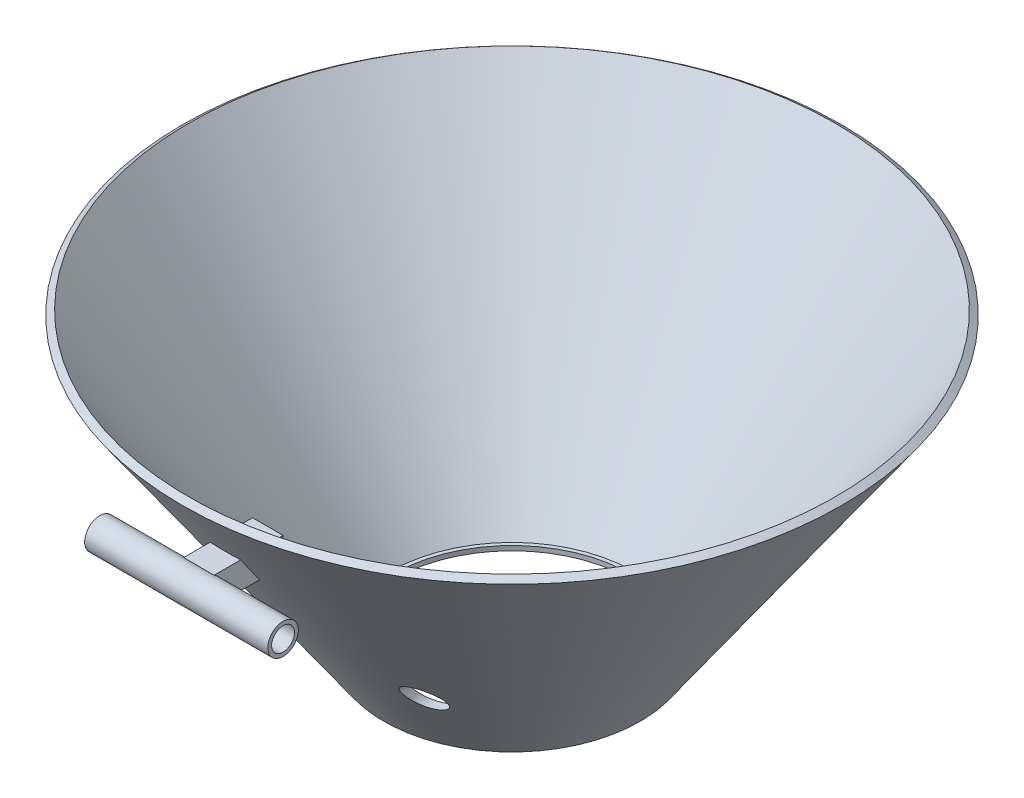
from build123d import *

# Parameters (mm, degrees)
CUT_EXTRUDE1_REACH       = 37.892
SKETCH4_R                = 7.75
BOSS_EXTRUDE1_DEPTH      = 3
BOSS_EXTRUDE1_DEPTH_BACK = 2
BOSS_EXTRUDE1_START      = 18
SKETCH13_W               = 2
SKETCH13_H               = 1.751149917
BOSS_EXTRUDE2_DEPTH      = 5
BOSS_EXTRUDE2_DEPTH_BACK = 7
SKETCH14_R               = 1
SKETCH15_R               = 0.75
CUT_EXTRUDE2_DEPTH       = 15
SKETCH16_R               = 1
CUT_EXTRUDE3_DEPTH       = 20


with BuildPart() as part:
    # Sketch3 → Revolve1 (revolve)
    with BuildSketch(Plane.XY):
        Polygon((8.400325033, 0), (21.601834058, 18.8537088), (21.192258036, 19.140497019), (8, 0.3), (0, 0.3), (0, 0), align=None)
    revolve(axis=Axis((0, 0, 0), (0, 1, 0)))

    # Sketch4 → Cut-Extrude1 (cut, up to next)
    with BuildSketch(Plane(origin=(0, 0.3, 0), x_dir=(1, 0, 0), z_dir=(0, 1, 0)), mode=Mode.PRIVATE) as cut_extrude1_sk1:
        Circle(SKETCH4_R)
    cut_extrude1_tool1 = extrude(cut_extrude1_sk1.sketch, amount=-CUT_EXTRUDE1_REACH, mode=Mode.PRIVATE) & part.part
    add(cut_extrude1_tool1.solids().sort_by_distance((0, 0.3, 0))[0], mode=Mode.SUBTRACT)

    # Sketch13 → Boss-Extrude1 (add, two sides: drawn at the far end of the back side and taken through both)
    with BuildSketch(Plane.XY.offset(BOSS_EXTRUDE1_START - BOSS_EXTRUDE1_DEPTH_BACK)):
        with Locations((0, 13.978133842)):
            Rectangle(SKETCH13_W, SKETCH13_H)
    extrude(amount=BOSS_EXTRUDE1_DEPTH + BOSS_EXTRUDE1_DEPTH_BACK)

    # Sketch14 → Boss-Extrude2 (add, two sides: drawn at the far end of the back side and taken through both)
    with BuildSketch(Plane.ZY.offset(1).offset(-BOSS_EXTRUDE2_DEPTH_BACK)):
        with Locations((21, 13.978133842)):
            Circle(SKETCH14_R)
    extrude(amount=BOSS_EXTRUDE2_DEPTH + BOSS_EXTRUDE2_DEPTH_BACK)

    # Sketch15 → Cut-Extrude2 (cut)
    with BuildSketch(Plane.ZY.offset(6)):
        with Locations((21, 13.978133842)):
            Circle(SKETCH15_R)
    extrude(amount=-CUT_EXTRUDE2_DEPTH, mode=Mode.SUBTRACT)

    # Sketch16 → Cut-Extrude3 (cut)
    with BuildSketch(Plane.XY):
        with Locations((-5, 5)):
            Circle(SKETCH16_R)
        with Locations((5, 5)):
            Circle(SKETCH16_R)
    extrude(amount=CUT_EXTRUDE3_DEPTH, mode=Mode.SUBTRACT)


solid = part.part
